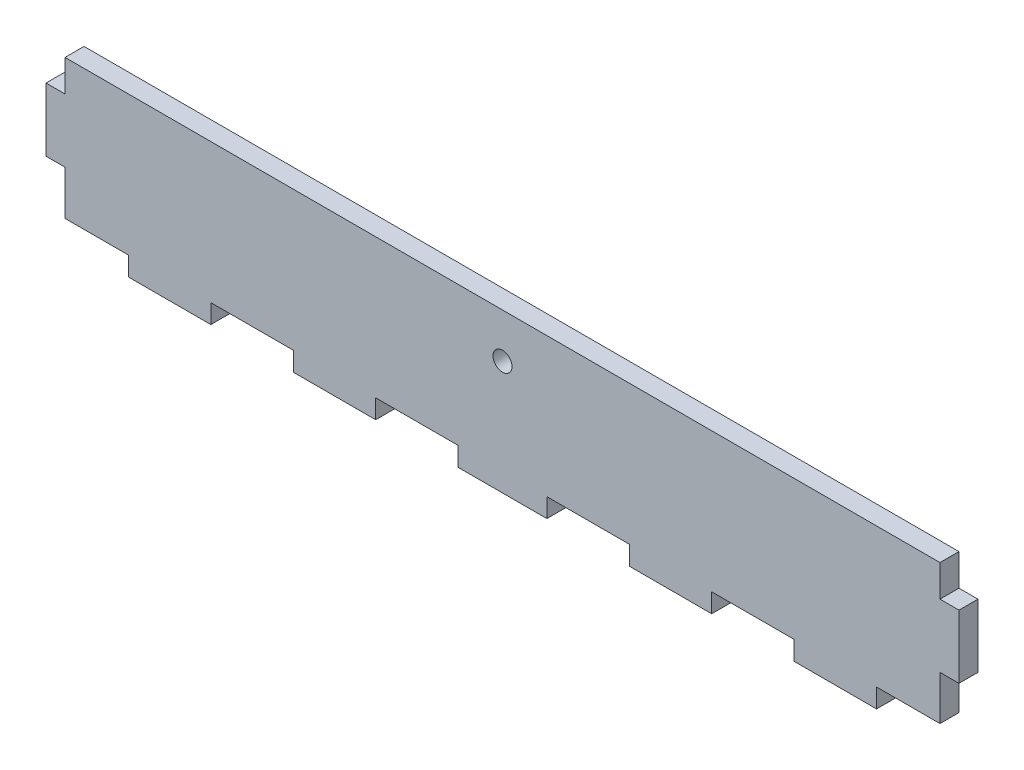
from build123d import *

# Parameters (mm, degrees)
SKETCH1_R           = 1.5
BOSS_EXTRUDE1_DEPTH = 3


with BuildPart() as part:
    # Sketch1 → Boss-Extrude1 (new body)
    with BuildSketch(Plane.XY):
        Polygon((0, 17), (0, 22), (138, 22), (138, 17), (141, 17), (141, 7), (138, 7), (138, 0), (128, 0), (128, -3), (115, -3), (115, 0), (102, 0), (102, -3), (89, -3), (89, 0), (76, 0), (76, -3), (62, -3), (62, 0), (49, 0), (49, -3), (36, -3), (36, 0), (23, 0), (23, -3), (10, -3), (10, 0), (0, 0), (0, 7), (-3, 7), (-3, 17), align=None)
        with Locations((69, 15)):
            Circle(SKETCH1_R, mode=Mode.SUBTRACT)
    extrude(amount=BOSS_EXTRUDE1_DEPTH)


solid = part.part
